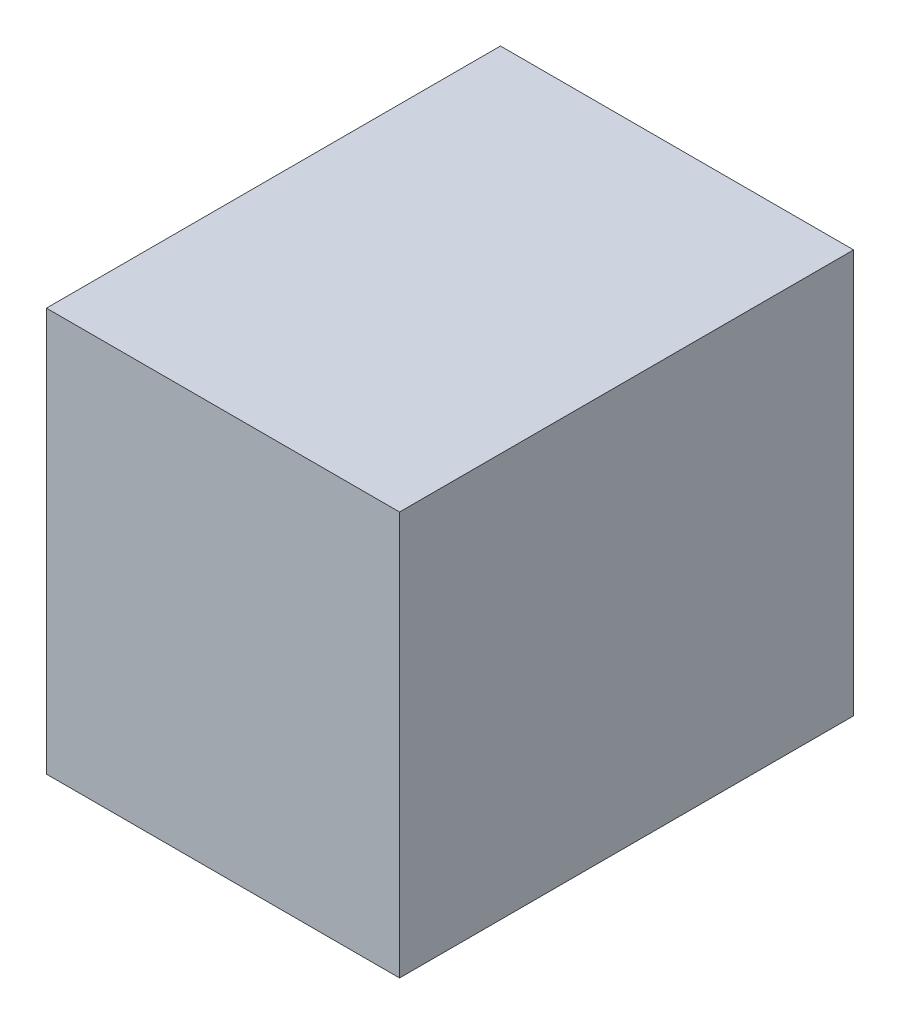
from build123d import *

# Parameters (mm, degrees)
SCHIZZO1_W                   = 35
SCHIZZO1_H                   = 40
ESTRUSIONE_ESTRUSIONE1_DEPTH = 45


with BuildPart() as part:
    # Schizzo1 → Estrusione-Estrusione1 (new body)
    with BuildSketch(Plane.XY):
        with Locations((17.5, 20)):
            Rectangle(SCHIZZO1_W, SCHIZZO1_H)
    extrude(amount=ESTRUSIONE_ESTRUSIONE1_DEPTH)


solid = part.part
